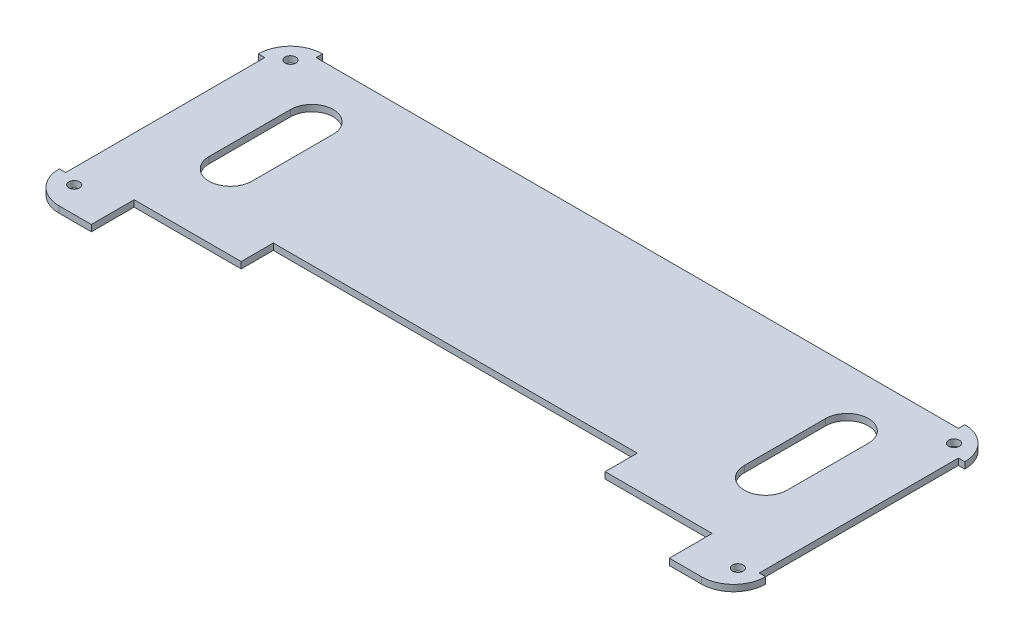
from build123d import *

# Parameters (mm, degrees)
ESQUISSE1_R      = 2.5
EXTRUSION1_DEPTH = 3
CONG_1_R         = 15
EXTRUSION2_REACH = 5
ESQUISSE2_W      = 3
ESQUISSE2_H      = 93
ESQUISSE2_W_2    = 300
ESQUISSE2_H_2    = 3


with BuildPart() as part:
    # Esquisse1 → Extrusion1 (new body)
    with BuildSketch(Plane(origin=(0, 0, 0), x_dir=(1, 0, 0), z_dir=(0, 1, 0))):
        Polygon((0, 0), (30, 0), (30, 20), (80, 20), (80, 35), (250, 35), (250, 20), (300, 20), (300, 0), (330, 0), (330, 123), (0, 123), align=None)
        with Locations((10, 113)):
            Circle(ESQUISSE1_R, mode=Mode.SUBTRACT)
        with Locations((320, 113)):
            Circle(ESQUISSE1_R, mode=Mode.SUBTRACT)
        with Locations((10, 12)):
            Circle(ESQUISSE1_R, mode=Mode.SUBTRACT)
        with Locations((320, 12)):
            Circle(ESQUISSE1_R, mode=Mode.SUBTRACT)
        with BuildLine():
            Line((300, 93), (300, 55))
            ThreePointArc((300, 55), (290, 45), (280, 55))
            Line((280, 55), (280, 93))
            ThreePointArc((280, 93), (290, 103), (300, 93))
        make_face(mode=Mode.SUBTRACT)
        with BuildLine():
            Line((30, 93), (30, 55))
            ThreePointArc((30, 55), (40, 45), (50, 55))
            Line((50, 55), (50, 93))
            ThreePointArc((50, 93), (40, 103), (30, 93))
        make_face(mode=Mode.SUBTRACT)
    extrude(amount=EXTRUSION1_DEPTH)

    # Congé1
    cong_1_edges = [part.edges().sort_by_distance(p)[0] for p in [
        (0, 1.5, -123),
        (330, 1.5, -123),
        (330, 1.5, 0),
        (0, 1.5, 0),
    ]]
    fillet(cong_1_edges, radius=CONG_1_R)

    # Esquisse2 → Extrusion2 (cut, up to next)
    with BuildSketch(Plane(origin=(0, 3, 0), x_dir=(1, 0, 0), z_dir=(0, 1, 0)), mode=Mode.PRIVATE) as extrusion2_sk1:
        with Locations((1.5, 61.5)):
            Rectangle(ESQUISSE2_W, ESQUISSE2_H)
    extrusion2_tool1 = extrude(extrusion2_sk1.sketch, amount=-EXTRUSION2_REACH, mode=Mode.PRIVATE) & part.part
    add(extrusion2_tool1.solids().sort_by_distance((1.5, 3, -61.5))[0], mode=Mode.SUBTRACT)
    # Esquisse2 → Extrusion2 (cut, up to next)
    with BuildSketch(Plane(origin=(0, 3, 0), x_dir=(1, 0, 0), z_dir=(0, 1, 0)), mode=Mode.PRIVATE) as extrusion2_sk2:
        with Locations((165, 121.5)):
            Rectangle(ESQUISSE2_W_2, ESQUISSE2_H_2)
    extrusion2_tool2 = extrude(extrusion2_sk2.sketch, amount=-EXTRUSION2_REACH, mode=Mode.PRIVATE) & part.part
    add(extrusion2_tool2.solids().sort_by_distance((165, 3, -121.5))[0], mode=Mode.SUBTRACT)
    # Esquisse2 → Extrusion2 (cut, up to next)
    with BuildSketch(Plane(origin=(0, 3, 0), x_dir=(1, 0, 0), z_dir=(0, 1, 0)), mode=Mode.PRIVATE) as extrusion2_sk3:
        with Locations((328.5, 61.5)):
            Rectangle(ESQUISSE2_W, ESQUISSE2_H)
    extrusion2_tool3 = extrude(extrusion2_sk3.sketch, amount=-EXTRUSION2_REACH, mode=Mode.PRIVATE) & part.part
    add(extrusion2_tool3.solids().sort_by_distance((328.5, 3, -61.5))[0], mode=Mode.SUBTRACT)


solid = part.part
